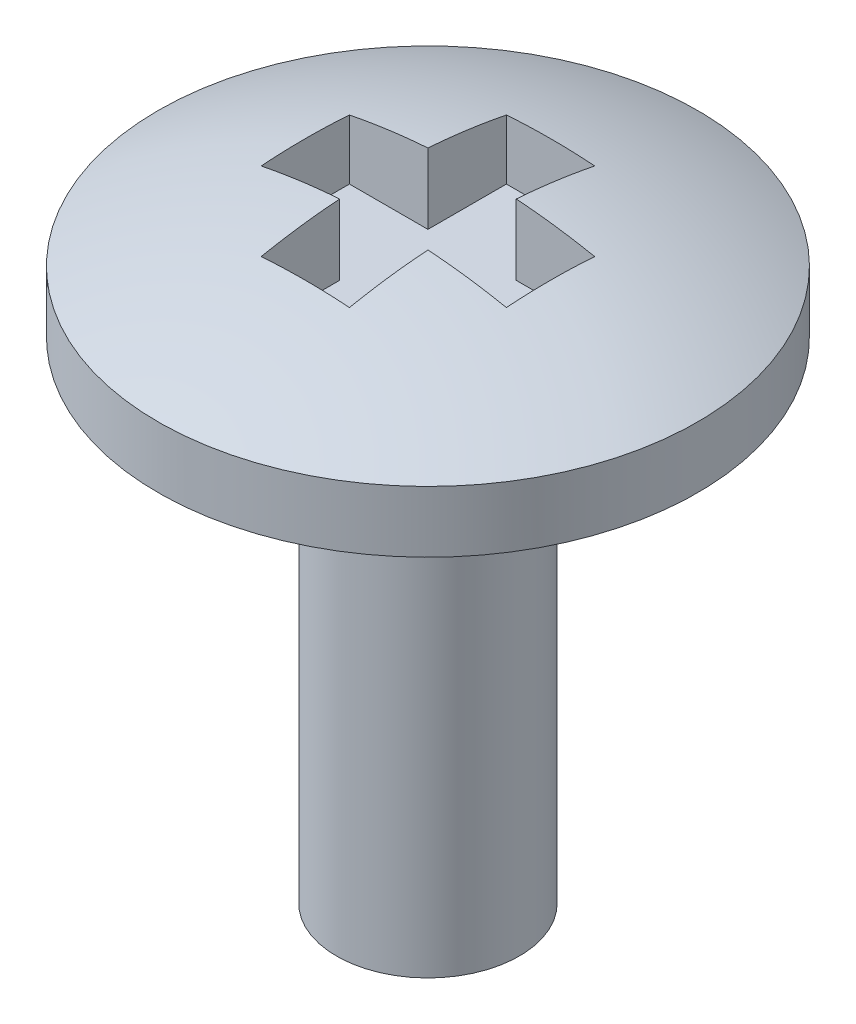
from build123d import *

# Parameters (mm, degrees)
EXTRUDE1_DEPTH = 2.54


with BuildPart() as part:
    # Sketch1 → Revolve1 (revolve)
    with BuildSketch(Plane.XY):
        with BuildLine():
            Line((0, 0), (0, -6.35))
            Line((0, -6.35), (0.946564988, -6.35))
            Line((0.946564988, -6.35), (0.946564988, -1.27))
            Line((0.946564988, -1.27), (2.794, -1.27))
            Line((2.794, -1.27), (2.794, -0.635))
            ThreePointArc((2.794, -0.635), (1.4326253, -0.16074868), (0, 0))
        make_face()
    revolve(axis=Axis((0, 0, 0), (0, -1, 0)))

    # Sketch2 → Extrude1 (cut)
    with BuildSketch(Plane.XZ.offset(0.762)):
        Polygon((0.4572, -1.27), (-0.4572, -1.27), (-0.4572, -0.4572), (-1.27, -0.4572), (-1.27, 0.4572), (-0.4572, 0.4572), (-0.4572, 1.27), (0.4572, 1.27), (0.4572, 0.4572), (1.27, 0.4572), (1.27, -0.4572), (0.4572, -0.4572), align=None)
    extrude(amount=-EXTRUDE1_DEPTH, mode=Mode.SUBTRACT)


solid = part.part
